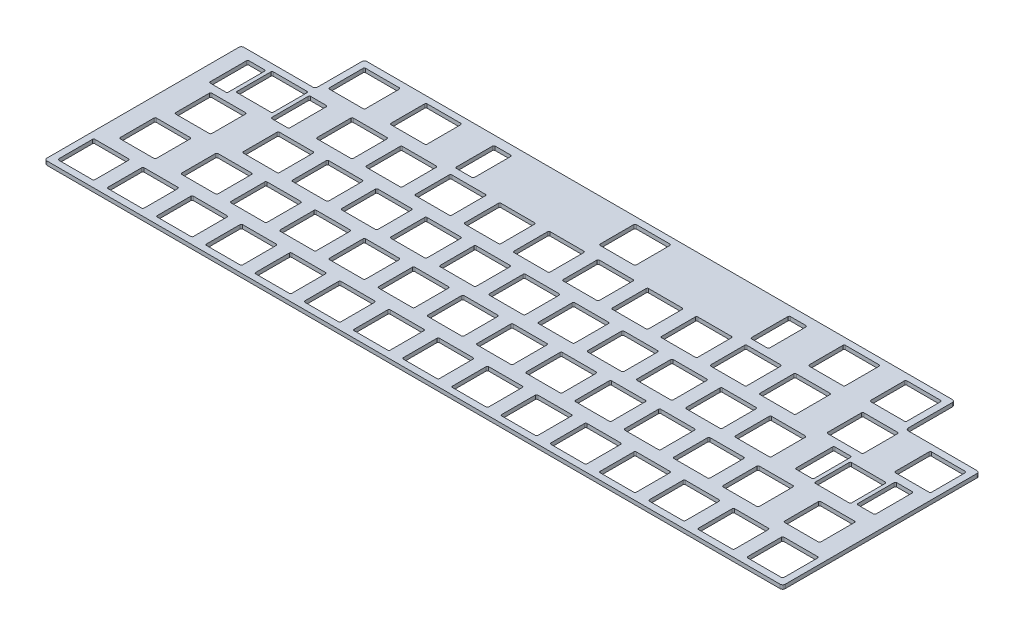
from build123d import *

# Parameters (mm, degrees)
BOSS_EXTRUDE1_DEPTH = 1.5


with BuildPart() as part:
    # Sketch2 → Boss-Extrude1 (new body)
    with BuildSketch(Plane.XZ):
        with BuildLine():
            Line((29.575, -95.25), (256.175, -95.25))
            ThreePointArc((256.175, -95.25), (256.882106781, -94.957106781), (257.175, -94.25))
            Line((257.175, -94.25), (257.175, -77.2))
            ThreePointArc((257.175, -77.2), (257.467893219, -76.492893219), (258.175, -76.2))
            Line((258.175, -76.2), (284.75, -76.2))
            ThreePointArc((284.75, -76.2), (285.457106781, -75.907106781), (285.75, -75.2))
            Line((285.75, -75.2), (285.75, -1))
            ThreePointArc((285.75, -1), (285.457106781, -0.292893219), (284.75, 0))
            Line((284.75, 0), (1, 0))
            ThreePointArc((1, 0), (0.292893219, -0.292893219), (0, -1))
            Line((0, -1), (0, -75.2))
            ThreePointArc((0, -75.2), (0.292893219, -75.907106781), (1, -76.2))
            Line((1, -76.2), (27.575, -76.2))
            ThreePointArc((27.575, -76.2), (28.282106781, -76.492893219), (28.575, -77.2))
            Line((28.575, -77.2), (28.575, -94.25))
            ThreePointArc((28.575, -94.25), (28.867893219, -94.957106781), (29.575, -95.25))
        make_face()
        with BuildLine():
            Line((3.025, -2.525), (16.025, -2.525))
            ThreePointArc((16.025, -2.525), (16.378553391, -2.671446609), (16.525, -3.025))
            Line((16.525, -3.025), (16.525, -16.025))
            ThreePointArc((16.525, -16.025), (16.378553391, -16.378553391), (16.025, -16.525))
            Line((16.025, -16.525), (3.025, -16.525))
            ThreePointArc((3.025, -16.525), (2.671446609, -16.378553391), (2.525, -16.025))
            Line((2.525, -16.025), (2.525, -3.025))
            ThreePointArc((2.525, -3.025), (2.671446609, -2.671446609), (3.025, -2.525))
        make_face(mode=Mode.SUBTRACT)
        with BuildLine():
            Line((22.075, -2.525), (35.075, -2.525))
            ThreePointArc((35.075, -2.525), (35.428553391, -2.671446609), (35.575, -3.025))
            Line((35.575, -3.025), (35.575, -16.025))
            ThreePointArc((35.575, -16.025), (35.428553391, -16.378553391), (35.075, -16.525))
            Line((35.075, -16.525), (22.075, -16.525))
            ThreePointArc((22.075, -16.525), (21.721446609, -16.378553391), (21.575, -16.025))
            Line((21.575, -16.025), (21.575, -3.025))
            ThreePointArc((21.575, -3.025), (21.721446609, -2.671446609), (22.075, -2.525))
        make_face(mode=Mode.SUBTRACT)
        with BuildLine():
            Line((41.125, -2.525), (54.125, -2.525))
            ThreePointArc((54.125, -2.525), (54.478553391, -2.671446609), (54.625, -3.025))
            Line((54.625, -3.025), (54.625, -16.025))
            ThreePointArc((54.625, -16.025), (54.478553391, -16.378553391), (54.125, -16.525))
            Line((54.125, -16.525), (41.125, -16.525))
            ThreePointArc((41.125, -16.525), (40.771446609, -16.378553391), (40.625, -16.025))
            Line((40.625, -16.025), (40.625, -3.025))
            ThreePointArc((40.625, -3.025), (40.771446609, -2.671446609), (41.125, -2.525))
        make_face(mode=Mode.SUBTRACT)
        with BuildLine():
            Line((60.175, -2.525), (73.175, -2.525))
            ThreePointArc((73.175, -2.525), (73.528553391, -2.671446609), (73.675, -3.025))
            Line((73.675, -3.025), (73.675, -16.025))
            ThreePointArc((73.675, -16.025), (73.528553391, -16.378553391), (73.175, -16.525))
            Line((73.175, -16.525), (60.175, -16.525))
            ThreePointArc((60.175, -16.525), (59.821446609, -16.378553391), (59.675, -16.025))
            Line((59.675, -16.025), (59.675, -3.025))
            ThreePointArc((59.675, -3.025), (59.821446609, -2.671446609), (60.175, -2.525))
        make_face(mode=Mode.SUBTRACT)
        with BuildLine():
            Line((79.225, -2.525), (92.225, -2.525))
            ThreePointArc((92.225, -2.525), (92.578553391, -2.671446609), (92.725, -3.025))
            Line((92.725, -3.025), (92.725, -16.025))
            ThreePointArc((92.725, -16.025), (92.578553391, -16.378553391), (92.225, -16.525))
            Line((92.225, -16.525), (79.225, -16.525))
            ThreePointArc((79.225, -16.525), (78.871446609, -16.378553391), (78.725, -16.025))
            Line((78.725, -16.025), (78.725, -3.025))
            ThreePointArc((78.725, -3.025), (78.871446609, -2.671446609), (79.225, -2.525))
        make_face(mode=Mode.SUBTRACT)
        with BuildLine():
            Line((98.275, -2.525), (111.275, -2.525))
            ThreePointArc((111.275, -2.525), (111.628553391, -2.671446609), (111.775, -3.025))
            Line((111.775, -3.025), (111.775, -16.025))
            ThreePointArc((111.775, -16.025), (111.628553391, -16.378553391), (111.275, -16.525))
            Line((111.275, -16.525), (98.275, -16.525))
            ThreePointArc((98.275, -16.525), (97.921446609, -16.378553391), (97.775, -16.025))
            Line((97.775, -16.025), (97.775, -3.025))
            ThreePointArc((97.775, -3.025), (97.921446609, -2.671446609), (98.275, -2.525))
        make_face(mode=Mode.SUBTRACT)
        with BuildLine():
            Line((117.325, -2.525), (130.325, -2.525))
            ThreePointArc((130.325, -2.525), (130.678553391, -2.671446609), (130.825, -3.025))
            Line((130.825, -3.025), (130.825, -16.025))
            ThreePointArc((130.825, -16.025), (130.678553391, -16.378553391), (130.325, -16.525))
            Line((130.325, -16.525), (117.325, -16.525))
            ThreePointArc((117.325, -16.525), (116.971446609, -16.378553391), (116.825, -16.025))
            Line((116.825, -16.025), (116.825, -3.025))
            ThreePointArc((116.825, -3.025), (116.971446609, -2.671446609), (117.325, -2.525))
        make_face(mode=Mode.SUBTRACT)
        with BuildLine():
            Line((136.375, -2.525), (149.375, -2.525))
            ThreePointArc((149.375, -2.525), (149.728553391, -2.671446609), (149.875, -3.025))
            Line((149.875, -3.025), (149.875, -16.025))
            ThreePointArc((149.875, -16.025), (149.728553391, -16.378553391), (149.375, -16.525))
            Line((149.375, -16.525), (136.375, -16.525))
            ThreePointArc((136.375, -16.525), (136.021446609, -16.378553391), (135.875, -16.025))
            Line((135.875, -16.025), (135.875, -3.025))
            ThreePointArc((135.875, -3.025), (136.021446609, -2.671446609), (136.375, -2.525))
        make_face(mode=Mode.SUBTRACT)
        with BuildLine():
            Line((155.425, -2.525), (168.425, -2.525))
            ThreePointArc((168.425, -2.525), (168.778553391, -2.671446609), (168.925, -3.025))
            Line((168.925, -3.025), (168.925, -16.025))
            ThreePointArc((168.925, -16.025), (168.778553391, -16.378553391), (168.425, -16.525))
            Line((168.425, -16.525), (155.425, -16.525))
            ThreePointArc((155.425, -16.525), (155.071446609, -16.378553391), (154.925, -16.025))
            Line((154.925, -16.025), (154.925, -3.025))
            ThreePointArc((154.925, -3.025), (155.071446609, -2.671446609), (155.425, -2.525))
        make_face(mode=Mode.SUBTRACT)
        with BuildLine():
            Line((174.475, -2.525), (187.475, -2.525))
            ThreePointArc((187.475, -2.525), (187.828553391, -2.671446609), (187.975, -3.025))
            Line((187.975, -3.025), (187.975, -16.025))
            ThreePointArc((187.975, -16.025), (187.828553391, -16.378553391), (187.475, -16.525))
            Line((187.475, -16.525), (174.475, -16.525))
            ThreePointArc((174.475, -16.525), (174.121446609, -16.378553391), (173.975, -16.025))
            Line((173.975, -16.025), (173.975, -3.025))
            ThreePointArc((173.975, -3.025), (174.121446609, -2.671446609), (174.475, -2.525))
        make_face(mode=Mode.SUBTRACT)
        with BuildLine():
            Line((193.525, -2.525), (206.525, -2.525))
            ThreePointArc((206.525, -2.525), (206.878553391, -2.671446609), (207.025, -3.025))
            Line((207.025, -3.025), (207.025, -16.025))
            ThreePointArc((207.025, -16.025), (206.878553391, -16.378553391), (206.525, -16.525))
            Line((206.525, -16.525), (193.525, -16.525))
            ThreePointArc((193.525, -16.525), (193.171446609, -16.378553391), (193.025, -16.025))
            Line((193.025, -16.025), (193.025, -3.025))
            ThreePointArc((193.025, -3.025), (193.171446609, -2.671446609), (193.525, -2.525))
        make_face(mode=Mode.SUBTRACT)
        with BuildLine():
            Line((212.575, -2.525), (225.575, -2.525))
            ThreePointArc((225.575, -2.525), (225.928553391, -2.671446609), (226.075, -3.025))
            Line((226.075, -3.025), (226.075, -16.025))
            ThreePointArc((226.075, -16.025), (225.928553391, -16.378553391), (225.575, -16.525))
            Line((225.575, -16.525), (212.575, -16.525))
            ThreePointArc((212.575, -16.525), (212.221446609, -16.378553391), (212.075, -16.025))
            Line((212.075, -16.025), (212.075, -3.025))
            ThreePointArc((212.075, -3.025), (212.221446609, -2.671446609), (212.575, -2.525))
        make_face(mode=Mode.SUBTRACT)
        with BuildLine():
            Line((231.625, -2.525), (244.625, -2.525))
            ThreePointArc((244.625, -2.525), (244.978553391, -2.671446609), (245.125, -3.025))
            Line((245.125, -3.025), (245.125, -16.025))
            ThreePointArc((245.125, -16.025), (244.978553391, -16.378553391), (244.625, -16.525))
            Line((244.625, -16.525), (231.625, -16.525))
            ThreePointArc((231.625, -16.525), (231.271446609, -16.378553391), (231.125, -16.025))
            Line((231.125, -16.025), (231.125, -3.025))
            ThreePointArc((231.125, -3.025), (231.271446609, -2.671446609), (231.625, -2.525))
        make_face(mode=Mode.SUBTRACT)
        with BuildLine():
            Line((250.675, -2.525), (263.675, -2.525))
            ThreePointArc((263.675, -2.525), (264.028553391, -2.671446609), (264.175, -3.025))
            Line((264.175, -3.025), (264.175, -16.025))
            ThreePointArc((264.175, -16.025), (264.028553391, -16.378553391), (263.675, -16.525))
            Line((263.675, -16.525), (250.675, -16.525))
            ThreePointArc((250.675, -16.525), (250.321446609, -16.378553391), (250.175, -16.025))
            Line((250.175, -16.025), (250.175, -3.025))
            ThreePointArc((250.175, -3.025), (250.321446609, -2.671446609), (250.675, -2.525))
        make_face(mode=Mode.SUBTRACT)
        with BuildLine():
            Line((269.725, -2.525), (282.725, -2.525))
            ThreePointArc((282.725, -2.525), (283.078553391, -2.671446609), (283.225, -3.025))
            Line((283.225, -3.025), (283.225, -16.025))
            ThreePointArc((283.225, -16.025), (283.078553391, -16.378553391), (282.725, -16.525))
            Line((282.725, -16.525), (269.725, -16.525))
            ThreePointArc((269.725, -16.525), (269.371446609, -16.378553391), (269.225, -16.025))
            Line((269.225, -16.025), (269.225, -3.025))
            ThreePointArc((269.225, -3.025), (269.371446609, -2.671446609), (269.725, -2.525))
        make_face(mode=Mode.SUBTRACT)
        with BuildLine():
            Line((7.7875, -21.575), (20.7875, -21.575))
            ThreePointArc((20.7875, -21.575), (21.141053391, -21.721446609), (21.2875, -22.075))
            Line((21.2875, -22.075), (21.2875, -35.075))
            ThreePointArc((21.2875, -35.075), (21.141053391, -35.428553391), (20.7875, -35.575))
            Line((20.7875, -35.575), (7.7875, -35.575))
            ThreePointArc((7.7875, -35.575), (7.433946609, -35.428553391), (7.2875, -35.075))
            Line((7.2875, -35.075), (7.2875, -22.075))
            ThreePointArc((7.2875, -22.075), (7.433946609, -21.721446609), (7.7875, -21.575))
        make_face(mode=Mode.SUBTRACT)
        with BuildLine():
            Line((31.6, -21.575), (44.6, -21.575))
            ThreePointArc((44.6, -21.575), (44.953553391, -21.721446609), (45.1, -22.075))
            Line((45.1, -22.075), (45.1, -35.075))
            ThreePointArc((45.1, -35.075), (44.953553391, -35.428553391), (44.6, -35.575))
            Line((44.6, -35.575), (31.6, -35.575))
            ThreePointArc((31.6, -35.575), (31.246446609, -35.428553391), (31.1, -35.075))
            Line((31.1, -35.075), (31.1, -22.075))
            ThreePointArc((31.1, -22.075), (31.246446609, -21.721446609), (31.6, -21.575))
        make_face(mode=Mode.SUBTRACT)
        with BuildLine():
            Line((50.65, -21.575), (63.65, -21.575))
            ThreePointArc((63.65, -21.575), (64.003553391, -21.721446609), (64.15, -22.075))
            Line((64.15, -22.075), (64.15, -35.075))
            ThreePointArc((64.15, -35.075), (64.003553391, -35.428553391), (63.65, -35.575))
            Line((63.65, -35.575), (50.65, -35.575))
            ThreePointArc((50.65, -35.575), (50.296446609, -35.428553391), (50.15, -35.075))
            Line((50.15, -35.075), (50.15, -22.075))
            ThreePointArc((50.15, -22.075), (50.296446609, -21.721446609), (50.65, -21.575))
        make_face(mode=Mode.SUBTRACT)
        with BuildLine():
            Line((69.7, -21.575), (82.7, -21.575))
            ThreePointArc((82.7, -21.575), (83.053553391, -21.721446609), (83.2, -22.075))
            Line((83.2, -22.075), (83.2, -35.075))
            ThreePointArc((83.2, -35.075), (83.053553391, -35.428553391), (82.7, -35.575))
            Line((82.7, -35.575), (69.7, -35.575))
            ThreePointArc((69.7, -35.575), (69.346446609, -35.428553391), (69.2, -35.075))
            Line((69.2, -35.075), (69.2, -22.075))
            ThreePointArc((69.2, -22.075), (69.346446609, -21.721446609), (69.7, -21.575))
        make_face(mode=Mode.SUBTRACT)
        with BuildLine():
            Line((88.75, -21.575), (101.75, -21.575))
            ThreePointArc((101.75, -21.575), (102.103553391, -21.721446609), (102.25, -22.075))
            Line((102.25, -22.075), (102.25, -35.075))
            ThreePointArc((102.25, -35.075), (102.103553391, -35.428553391), (101.75, -35.575))
            Line((101.75, -35.575), (88.75, -35.575))
            ThreePointArc((88.75, -35.575), (88.396446609, -35.428553391), (88.25, -35.075))
            Line((88.25, -35.075), (88.25, -22.075))
            ThreePointArc((88.25, -22.075), (88.396446609, -21.721446609), (88.75, -21.575))
        make_face(mode=Mode.SUBTRACT)
        with BuildLine():
            Line((107.8, -21.575), (120.8, -21.575))
            ThreePointArc((120.8, -21.575), (121.153553391, -21.721446609), (121.3, -22.075))
            Line((121.3, -22.075), (121.3, -35.075))
            ThreePointArc((121.3, -35.075), (121.153553391, -35.428553391), (120.8, -35.575))
            Line((120.8, -35.575), (107.8, -35.575))
            ThreePointArc((107.8, -35.575), (107.446446609, -35.428553391), (107.3, -35.075))
            Line((107.3, -35.075), (107.3, -22.075))
            ThreePointArc((107.3, -22.075), (107.446446609, -21.721446609), (107.8, -21.575))
        make_face(mode=Mode.SUBTRACT)
        with BuildLine():
            Line((126.85, -21.575), (139.85, -21.575))
            ThreePointArc((139.85, -21.575), (140.203553391, -21.721446609), (140.35, -22.075))
            Line((140.35, -22.075), (140.35, -35.075))
            ThreePointArc((140.35, -35.075), (140.203553391, -35.428553391), (139.85, -35.575))
            Line((139.85, -35.575), (126.85, -35.575))
            ThreePointArc((126.85, -35.575), (126.496446609, -35.428553391), (126.35, -35.075))
            Line((126.35, -35.075), (126.35, -22.075))
            ThreePointArc((126.35, -22.075), (126.496446609, -21.721446609), (126.85, -21.575))
        make_face(mode=Mode.SUBTRACT)
        with BuildLine():
            Line((145.9, -21.575), (158.9, -21.575))
            ThreePointArc((158.9, -21.575), (159.253553391, -21.721446609), (159.4, -22.075))
            Line((159.4, -22.075), (159.4, -35.075))
            ThreePointArc((159.4, -35.075), (159.253553391, -35.428553391), (158.9, -35.575))
            Line((158.9, -35.575), (145.9, -35.575))
            ThreePointArc((145.9, -35.575), (145.546446609, -35.428553391), (145.4, -35.075))
            Line((145.4, -35.075), (145.4, -22.075))
            ThreePointArc((145.4, -22.075), (145.546446609, -21.721446609), (145.9, -21.575))
        make_face(mode=Mode.SUBTRACT)
        with BuildLine():
            Line((164.95, -21.575), (177.95, -21.575))
            ThreePointArc((177.95, -21.575), (178.303553391, -21.721446609), (178.45, -22.075))
            Line((178.45, -22.075), (178.45, -35.075))
            ThreePointArc((178.45, -35.075), (178.303553391, -35.428553391), (177.95, -35.575))
            Line((177.95, -35.575), (164.95, -35.575))
            ThreePointArc((164.95, -35.575), (164.596446609, -35.428553391), (164.45, -35.075))
            Line((164.45, -35.075), (164.45, -22.075))
            ThreePointArc((164.45, -22.075), (164.596446609, -21.721446609), (164.95, -21.575))
        make_face(mode=Mode.SUBTRACT)
        with BuildLine():
            Line((184, -21.575), (197, -21.575))
            ThreePointArc((197, -21.575), (197.353553391, -21.721446609), (197.5, -22.075))
            Line((197.5, -22.075), (197.5, -35.075))
            ThreePointArc((197.5, -35.075), (197.353553391, -35.428553391), (197, -35.575))
            Line((197, -35.575), (184, -35.575))
            ThreePointArc((184, -35.575), (183.646446609, -35.428553391), (183.5, -35.075))
            Line((183.5, -35.075), (183.5, -22.075))
            ThreePointArc((183.5, -22.075), (183.646446609, -21.721446609), (184, -21.575))
        make_face(mode=Mode.SUBTRACT)
        with BuildLine():
            Line((203.05, -21.575), (216.05, -21.575))
            ThreePointArc((216.05, -21.575), (216.403553391, -21.721446609), (216.55, -22.075))
            Line((216.55, -22.075), (216.55, -35.075))
            ThreePointArc((216.55, -35.075), (216.403553391, -35.428553391), (216.05, -35.575))
            Line((216.05, -35.575), (203.05, -35.575))
            ThreePointArc((203.05, -35.575), (202.696446609, -35.428553391), (202.55, -35.075))
            Line((202.55, -35.075), (202.55, -22.075))
            ThreePointArc((202.55, -22.075), (202.696446609, -21.721446609), (203.05, -21.575))
        make_face(mode=Mode.SUBTRACT)
        with BuildLine():
            Line((222.1, -21.575), (235.1, -21.575))
            ThreePointArc((235.1, -21.575), (235.453553391, -21.721446609), (235.6, -22.075))
            Line((235.6, -22.075), (235.6, -35.075))
            ThreePointArc((235.6, -35.075), (235.453553391, -35.428553391), (235.1, -35.575))
            Line((235.1, -35.575), (222.1, -35.575))
            ThreePointArc((222.1, -35.575), (221.746446609, -35.428553391), (221.6, -35.075))
            Line((221.6, -35.075), (221.6, -22.075))
            ThreePointArc((221.6, -22.075), (221.746446609, -21.721446609), (222.1, -21.575))
        make_face(mode=Mode.SUBTRACT)
        with BuildLine():
            Line((241.15, -21.575), (254.15, -21.575))
            ThreePointArc((254.15, -21.575), (254.503553391, -21.721446609), (254.65, -22.075))
            Line((254.65, -22.075), (254.65, -35.075))
            ThreePointArc((254.65, -35.075), (254.503553391, -35.428553391), (254.15, -35.575))
            Line((254.15, -35.575), (241.15, -35.575))
            ThreePointArc((241.15, -35.575), (240.796446609, -35.428553391), (240.65, -35.075))
            Line((240.65, -35.075), (240.65, -22.075))
            ThreePointArc((240.65, -22.075), (240.796446609, -21.721446609), (241.15, -21.575))
        make_face(mode=Mode.SUBTRACT)
        with BuildLine():
            Line((264.9625, -21.575), (277.9625, -21.575))
            ThreePointArc((277.9625, -21.575), (278.316053391, -21.721446609), (278.4625, -22.075))
            Line((278.4625, -22.075), (278.4625, -35.075))
            ThreePointArc((278.4625, -35.075), (278.316053391, -35.428553391), (277.9625, -35.575))
            Line((277.9625, -35.575), (264.9625, -35.575))
            ThreePointArc((264.9625, -35.575), (264.608946609, -35.428553391), (264.4625, -35.075))
            Line((264.4625, -35.075), (264.4625, -22.075))
            ThreePointArc((264.4625, -22.075), (264.608946609, -21.721446609), (264.9625, -21.575))
        make_face(mode=Mode.SUBTRACT)
        with BuildLine():
            Line((10.16875, -40.625), (23.16875, -40.625))
            ThreePointArc((23.16875, -40.625), (23.522303391, -40.771446609), (23.66875, -41.125))
            Line((23.66875, -41.125), (23.66875, -54.125))
            ThreePointArc((23.66875, -54.125), (23.522303391, -54.478553391), (23.16875, -54.625))
            Line((23.16875, -54.625), (10.16875, -54.625))
            ThreePointArc((10.16875, -54.625), (9.815196609, -54.478553391), (9.66875, -54.125))
            Line((9.66875, -54.125), (9.66875, -41.125))
            ThreePointArc((9.66875, -41.125), (9.815196609, -40.771446609), (10.16875, -40.625))
        make_face(mode=Mode.SUBTRACT)
        with BuildLine():
            Line((36.3625, -40.625), (49.3625, -40.625))
            ThreePointArc((49.3625, -40.625), (49.716053391, -40.771446609), (49.8625, -41.125))
            Line((49.8625, -41.125), (49.8625, -54.125))
            ThreePointArc((49.8625, -54.125), (49.716053391, -54.478553391), (49.3625, -54.625))
            Line((49.3625, -54.625), (36.3625, -54.625))
            ThreePointArc((36.3625, -54.625), (36.008946609, -54.478553391), (35.8625, -54.125))
            Line((35.8625, -54.125), (35.8625, -41.125))
            ThreePointArc((35.8625, -41.125), (36.008946609, -40.771446609), (36.3625, -40.625))
        make_face(mode=Mode.SUBTRACT)
        with BuildLine():
            Line((55.4125, -40.625), (68.4125, -40.625))
            ThreePointArc((68.4125, -40.625), (68.766053391, -40.771446609), (68.9125, -41.125))
            Line((68.9125, -41.125), (68.9125, -54.125))
            ThreePointArc((68.9125, -54.125), (68.766053391, -54.478553391), (68.4125, -54.625))
            Line((68.4125, -54.625), (55.4125, -54.625))
            ThreePointArc((55.4125, -54.625), (55.058946609, -54.478553391), (54.9125, -54.125))
            Line((54.9125, -54.125), (54.9125, -41.125))
            ThreePointArc((54.9125, -41.125), (55.058946609, -40.771446609), (55.4125, -40.625))
        make_face(mode=Mode.SUBTRACT)
        with BuildLine():
            Line((74.4625, -40.625), (87.4625, -40.625))
            ThreePointArc((87.4625, -40.625), (87.816053391, -40.771446609), (87.9625, -41.125))
            Line((87.9625, -41.125), (87.9625, -54.125))
            ThreePointArc((87.9625, -54.125), (87.816053391, -54.478553391), (87.4625, -54.625))
            Line((87.4625, -54.625), (74.4625, -54.625))
            ThreePointArc((74.4625, -54.625), (74.108946609, -54.478553391), (73.9625, -54.125))
            Line((73.9625, -54.125), (73.9625, -41.125))
            ThreePointArc((73.9625, -41.125), (74.108946609, -40.771446609), (74.4625, -40.625))
        make_face(mode=Mode.SUBTRACT)
        with BuildLine():
            Line((93.5125, -40.625), (106.5125, -40.625))
            ThreePointArc((106.5125, -40.625), (106.866053391, -40.771446609), (107.0125, -41.125))
            Line((107.0125, -41.125), (107.0125, -54.125))
            ThreePointArc((107.0125, -54.125), (106.866053391, -54.478553391), (106.5125, -54.625))
            Line((106.5125, -54.625), (93.5125, -54.625))
            ThreePointArc((93.5125, -54.625), (93.158946609, -54.478553391), (93.0125, -54.125))
            Line((93.0125, -54.125), (93.0125, -41.125))
            ThreePointArc((93.0125, -41.125), (93.158946609, -40.771446609), (93.5125, -40.625))
        make_face(mode=Mode.SUBTRACT)
        with BuildLine():
            Line((112.5625, -40.625), (125.5625, -40.625))
            ThreePointArc((125.5625, -40.625), (125.916053391, -40.771446609), (126.0625, -41.125))
            Line((126.0625, -41.125), (126.0625, -54.125))
            ThreePointArc((126.0625, -54.125), (125.916053391, -54.478553391), (125.5625, -54.625))
            Line((125.5625, -54.625), (112.5625, -54.625))
            ThreePointArc((112.5625, -54.625), (112.208946609, -54.478553391), (112.0625, -54.125))
            Line((112.0625, -54.125), (112.0625, -41.125))
            ThreePointArc((112.0625, -41.125), (112.208946609, -40.771446609), (112.5625, -40.625))
        make_face(mode=Mode.SUBTRACT)
        with BuildLine():
            Line((131.6125, -40.625), (144.6125, -40.625))
            ThreePointArc((144.6125, -40.625), (144.966053391, -40.771446609), (145.1125, -41.125))
            Line((145.1125, -41.125), (145.1125, -54.125))
            ThreePointArc((145.1125, -54.125), (144.966053391, -54.478553391), (144.6125, -54.625))
            Line((144.6125, -54.625), (131.6125, -54.625))
            ThreePointArc((131.6125, -54.625), (131.258946609, -54.478553391), (131.1125, -54.125))
            Line((131.1125, -54.125), (131.1125, -41.125))
            ThreePointArc((131.1125, -41.125), (131.258946609, -40.771446609), (131.6125, -40.625))
        make_face(mode=Mode.SUBTRACT)
        with BuildLine():
            Line((150.6625, -40.625), (163.6625, -40.625))
            ThreePointArc((163.6625, -40.625), (164.016053391, -40.771446609), (164.1625, -41.125))
            Line((164.1625, -41.125), (164.1625, -54.125))
            ThreePointArc((164.1625, -54.125), (164.016053391, -54.478553391), (163.6625, -54.625))
            Line((163.6625, -54.625), (150.6625, -54.625))
            ThreePointArc((150.6625, -54.625), (150.308946609, -54.478553391), (150.1625, -54.125))
            Line((150.1625, -54.125), (150.1625, -41.125))
            ThreePointArc((150.1625, -41.125), (150.308946609, -40.771446609), (150.6625, -40.625))
        make_face(mode=Mode.SUBTRACT)
        with BuildLine():
            Line((169.7125, -40.625), (182.7125, -40.625))
            ThreePointArc((182.7125, -40.625), (183.066053391, -40.771446609), (183.2125, -41.125))
            Line((183.2125, -41.125), (183.2125, -54.125))
            ThreePointArc((183.2125, -54.125), (183.066053391, -54.478553391), (182.7125, -54.625))
            Line((182.7125, -54.625), (169.7125, -54.625))
            ThreePointArc((169.7125, -54.625), (169.358946609, -54.478553391), (169.2125, -54.125))
            Line((169.2125, -54.125), (169.2125, -41.125))
            ThreePointArc((169.2125, -41.125), (169.358946609, -40.771446609), (169.7125, -40.625))
        make_face(mode=Mode.SUBTRACT)
        with BuildLine():
            Line((188.7625, -40.625), (201.7625, -40.625))
            ThreePointArc((201.7625, -40.625), (202.116053391, -40.771446609), (202.2625, -41.125))
            Line((202.2625, -41.125), (202.2625, -54.125))
            ThreePointArc((202.2625, -54.125), (202.116053391, -54.478553391), (201.7625, -54.625))
            Line((201.7625, -54.625), (188.7625, -54.625))
            ThreePointArc((188.7625, -54.625), (188.408946609, -54.478553391), (188.2625, -54.125))
            Line((188.2625, -54.125), (188.2625, -41.125))
            ThreePointArc((188.2625, -41.125), (188.408946609, -40.771446609), (188.7625, -40.625))
        make_face(mode=Mode.SUBTRACT)
        with BuildLine():
            Line((207.8125, -40.625), (220.8125, -40.625))
            ThreePointArc((220.8125, -40.625), (221.166053391, -40.771446609), (221.3125, -41.125))
            Line((221.3125, -41.125), (221.3125, -54.125))
            ThreePointArc((221.3125, -54.125), (221.166053391, -54.478553391), (220.8125, -54.625))
            Line((220.8125, -54.625), (207.8125, -54.625))
            ThreePointArc((207.8125, -54.625), (207.458946609, -54.478553391), (207.3125, -54.125))
            Line((207.3125, -54.125), (207.3125, -41.125))
            ThreePointArc((207.3125, -41.125), (207.458946609, -40.771446609), (207.8125, -40.625))
        make_face(mode=Mode.SUBTRACT)
        with BuildLine():
            Line((226.8625, -40.625), (239.8625, -40.625))
            ThreePointArc((239.8625, -40.625), (240.216053391, -40.771446609), (240.3625, -41.125))
            Line((240.3625, -41.125), (240.3625, -54.125))
            ThreePointArc((240.3625, -54.125), (240.216053391, -54.478553391), (239.8625, -54.625))
            Line((239.8625, -54.625), (226.8625, -54.625))
            ThreePointArc((226.8625, -54.625), (226.508946609, -54.478553391), (226.3625, -54.125))
            Line((226.3625, -54.125), (226.3625, -41.125))
            ThreePointArc((226.3625, -41.125), (226.508946609, -40.771446609), (226.8625, -40.625))
        make_face(mode=Mode.SUBTRACT)
        with BuildLine():
            Line((257.81875, -40.625), (270.81875, -40.625))
            ThreePointArc((270.81875, -40.625), (271.172303391, -40.771446609), (271.31875, -41.125))
            Line((271.31875, -41.125), (271.31875, -54.125))
            ThreePointArc((271.31875, -54.125), (271.172303391, -54.478553391), (270.81875, -54.625))
            Line((270.81875, -54.625), (257.81875, -54.625))
            ThreePointArc((257.81875, -54.625), (257.465196609, -54.478553391), (257.31875, -54.125))
            Line((257.31875, -54.125), (257.31875, -41.125))
            ThreePointArc((257.31875, -41.125), (257.465196609, -40.771446609), (257.81875, -40.625))
        make_face(mode=Mode.SUBTRACT)
        with BuildLine():
            Line((249.38075, -41.625), (255.38075, -41.625))
            ThreePointArc((255.38075, -41.625), (255.734303391, -41.771446609), (255.88075, -42.125))
            Line((255.88075, -42.125), (255.88075, -56.125))
            ThreePointArc((255.88075, -56.125), (255.734303391, -56.478553391), (255.38075, -56.625))
            Line((255.38075, -56.625), (249.38075, -56.625))
            ThreePointArc((249.38075, -56.625), (249.027196609, -56.478553391), (248.88075, -56.125))
            Line((248.88075, -56.125), (248.88075, -42.125))
            ThreePointArc((248.88075, -42.125), (249.027196609, -41.771446609), (249.38075, -41.625))
        make_face(mode=Mode.SUBTRACT)
        with BuildLine():
            Line((273.25675, -41.625), (279.25675, -41.625))
            ThreePointArc((279.25675, -41.625), (279.610303391, -41.771446609), (279.75675, -42.125))
            Line((279.75675, -42.125), (279.75675, -56.125))
            ThreePointArc((279.75675, -56.125), (279.610303391, -56.478553391), (279.25675, -56.625))
            Line((279.25675, -56.625), (273.25675, -56.625))
            ThreePointArc((273.25675, -56.625), (272.903196609, -56.478553391), (272.75675, -56.125))
            Line((272.75675, -56.125), (272.75675, -42.125))
            ThreePointArc((272.75675, -42.125), (272.903196609, -41.771446609), (273.25675, -41.625))
        make_face(mode=Mode.SUBTRACT)
        with BuildLine():
            Line((14.93125, -59.675), (27.93125, -59.675))
            ThreePointArc((27.93125, -59.675), (28.284803391, -59.821446609), (28.43125, -60.175))
            Line((28.43125, -60.175), (28.43125, -73.175))
            ThreePointArc((28.43125, -73.175), (28.284803391, -73.528553391), (27.93125, -73.675))
            Line((27.93125, -73.675), (14.93125, -73.675))
            ThreePointArc((14.93125, -73.675), (14.577696609, -73.528553391), (14.43125, -73.175))
            Line((14.43125, -73.175), (14.43125, -60.175))
            ThreePointArc((14.43125, -60.175), (14.577696609, -59.821446609), (14.93125, -59.675))
        make_face(mode=Mode.SUBTRACT)
        with BuildLine():
            Line((36.36925, -72.675), (30.36925, -72.675))
            ThreePointArc((30.36925, -72.675), (30.015696609, -72.528553391), (29.86925, -72.175))
            Line((29.86925, -72.175), (29.86925, -58.175))
            ThreePointArc((29.86925, -58.175), (30.015696609, -57.821446609), (30.36925, -57.675))
            Line((30.36925, -57.675), (36.36925, -57.675))
            ThreePointArc((36.36925, -57.675), (36.722803391, -57.821446609), (36.86925, -58.175))
            Line((36.86925, -58.175), (36.86925, -72.175))
            ThreePointArc((36.86925, -72.175), (36.722803391, -72.528553391), (36.36925, -72.675))
        make_face(mode=Mode.SUBTRACT)
        with BuildLine():
            Line((12.49325, -72.675), (6.49325, -72.675))
            ThreePointArc((6.49325, -72.675), (6.139696609, -72.528553391), (5.99325, -72.175))
            Line((5.99325, -72.175), (5.99325, -58.175))
            ThreePointArc((5.99325, -58.175), (6.139696609, -57.821446609), (6.49325, -57.675))
            Line((6.49325, -57.675), (12.49325, -57.675))
            ThreePointArc((12.49325, -57.675), (12.846803391, -57.821446609), (12.99325, -58.175))
            Line((12.99325, -58.175), (12.99325, -72.175))
            ThreePointArc((12.99325, -72.175), (12.846803391, -72.528553391), (12.49325, -72.675))
        make_face(mode=Mode.SUBTRACT)
        with BuildLine():
            Line((45.8875, -59.675), (58.8875, -59.675))
            ThreePointArc((58.8875, -59.675), (59.241053391, -59.821446609), (59.3875, -60.175))
            Line((59.3875, -60.175), (59.3875, -73.175))
            ThreePointArc((59.3875, -73.175), (59.241053391, -73.528553391), (58.8875, -73.675))
            Line((58.8875, -73.675), (45.8875, -73.675))
            ThreePointArc((45.8875, -73.675), (45.533946609, -73.528553391), (45.3875, -73.175))
            Line((45.3875, -73.175), (45.3875, -60.175))
            ThreePointArc((45.3875, -60.175), (45.533946609, -59.821446609), (45.8875, -59.675))
        make_face(mode=Mode.SUBTRACT)
        with BuildLine():
            Line((64.9375, -59.675), (77.9375, -59.675))
            ThreePointArc((77.9375, -59.675), (78.291053391, -59.821446609), (78.4375, -60.175))
            Line((78.4375, -60.175), (78.4375, -73.175))
            ThreePointArc((78.4375, -73.175), (78.291053391, -73.528553391), (77.9375, -73.675))
            Line((77.9375, -73.675), (64.9375, -73.675))
            ThreePointArc((64.9375, -73.675), (64.583946609, -73.528553391), (64.4375, -73.175))
            Line((64.4375, -73.175), (64.4375, -60.175))
            ThreePointArc((64.4375, -60.175), (64.583946609, -59.821446609), (64.9375, -59.675))
        make_face(mode=Mode.SUBTRACT)
        with BuildLine():
            Line((83.9875, -59.675), (96.9875, -59.675))
            ThreePointArc((96.9875, -59.675), (97.341053391, -59.821446609), (97.4875, -60.175))
            Line((97.4875, -60.175), (97.4875, -73.175))
            ThreePointArc((97.4875, -73.175), (97.341053391, -73.528553391), (96.9875, -73.675))
            Line((96.9875, -73.675), (83.9875, -73.675))
            ThreePointArc((83.9875, -73.675), (83.633946609, -73.528553391), (83.4875, -73.175))
            Line((83.4875, -73.175), (83.4875, -60.175))
            ThreePointArc((83.4875, -60.175), (83.633946609, -59.821446609), (83.9875, -59.675))
        make_face(mode=Mode.SUBTRACT)
        with BuildLine():
            Line((103.0375, -59.675), (116.0375, -59.675))
            ThreePointArc((116.0375, -59.675), (116.391053391, -59.821446609), (116.5375, -60.175))
            Line((116.5375, -60.175), (116.5375, -73.175))
            ThreePointArc((116.5375, -73.175), (116.391053391, -73.528553391), (116.0375, -73.675))
            Line((116.0375, -73.675), (103.0375, -73.675))
            ThreePointArc((103.0375, -73.675), (102.683946609, -73.528553391), (102.5375, -73.175))
            Line((102.5375, -73.175), (102.5375, -60.175))
            ThreePointArc((102.5375, -60.175), (102.683946609, -59.821446609), (103.0375, -59.675))
        make_face(mode=Mode.SUBTRACT)
        with BuildLine():
            Line((122.0875, -59.675), (135.0875, -59.675))
            ThreePointArc((135.0875, -59.675), (135.441053391, -59.821446609), (135.5875, -60.175))
            Line((135.5875, -60.175), (135.5875, -73.175))
            ThreePointArc((135.5875, -73.175), (135.441053391, -73.528553391), (135.0875, -73.675))
            Line((135.0875, -73.675), (122.0875, -73.675))
            ThreePointArc((122.0875, -73.675), (121.733946609, -73.528553391), (121.5875, -73.175))
            Line((121.5875, -73.175), (121.5875, -60.175))
            ThreePointArc((121.5875, -60.175), (121.733946609, -59.821446609), (122.0875, -59.675))
        make_face(mode=Mode.SUBTRACT)
        with BuildLine():
            Line((141.1375, -59.675), (154.1375, -59.675))
            ThreePointArc((154.1375, -59.675), (154.491053391, -59.821446609), (154.6375, -60.175))
            Line((154.6375, -60.175), (154.6375, -73.175))
            ThreePointArc((154.6375, -73.175), (154.491053391, -73.528553391), (154.1375, -73.675))
            Line((154.1375, -73.675), (141.1375, -73.675))
            ThreePointArc((141.1375, -73.675), (140.783946609, -73.528553391), (140.6375, -73.175))
            Line((140.6375, -73.175), (140.6375, -60.175))
            ThreePointArc((140.6375, -60.175), (140.783946609, -59.821446609), (141.1375, -59.675))
        make_face(mode=Mode.SUBTRACT)
        with BuildLine():
            Line((160.1875, -59.675), (173.1875, -59.675))
            ThreePointArc((173.1875, -59.675), (173.541053391, -59.821446609), (173.6875, -60.175))
            Line((173.6875, -60.175), (173.6875, -73.175))
            ThreePointArc((173.6875, -73.175), (173.541053391, -73.528553391), (173.1875, -73.675))
            Line((173.1875, -73.675), (160.1875, -73.675))
            ThreePointArc((160.1875, -73.675), (159.833946609, -73.528553391), (159.6875, -73.175))
            Line((159.6875, -73.175), (159.6875, -60.175))
            ThreePointArc((159.6875, -60.175), (159.833946609, -59.821446609), (160.1875, -59.675))
        make_face(mode=Mode.SUBTRACT)
        with BuildLine():
            Line((179.2375, -59.675), (192.2375, -59.675))
            ThreePointArc((192.2375, -59.675), (192.591053391, -59.821446609), (192.7375, -60.175))
            Line((192.7375, -60.175), (192.7375, -73.175))
            ThreePointArc((192.7375, -73.175), (192.591053391, -73.528553391), (192.2375, -73.675))
            Line((192.2375, -73.675), (179.2375, -73.675))
            ThreePointArc((179.2375, -73.675), (178.883946609, -73.528553391), (178.7375, -73.175))
            Line((178.7375, -73.175), (178.7375, -60.175))
            ThreePointArc((178.7375, -60.175), (178.883946609, -59.821446609), (179.2375, -59.675))
        make_face(mode=Mode.SUBTRACT)
        with BuildLine():
            Line((198.2875, -59.675), (211.2875, -59.675))
            ThreePointArc((211.2875, -59.675), (211.641053391, -59.821446609), (211.7875, -60.175))
            Line((211.7875, -60.175), (211.7875, -73.175))
            ThreePointArc((211.7875, -73.175), (211.641053391, -73.528553391), (211.2875, -73.675))
            Line((211.2875, -73.675), (198.2875, -73.675))
            ThreePointArc((198.2875, -73.675), (197.933946609, -73.528553391), (197.7875, -73.175))
            Line((197.7875, -73.175), (197.7875, -60.175))
            ThreePointArc((197.7875, -60.175), (197.933946609, -59.821446609), (198.2875, -59.675))
        make_face(mode=Mode.SUBTRACT)
        with BuildLine():
            Line((217.3375, -59.675), (230.3375, -59.675))
            ThreePointArc((230.3375, -59.675), (230.691053391, -59.821446609), (230.8375, -60.175))
            Line((230.8375, -60.175), (230.8375, -73.175))
            ThreePointArc((230.8375, -73.175), (230.691053391, -73.528553391), (230.3375, -73.675))
            Line((230.3375, -73.675), (217.3375, -73.675))
            ThreePointArc((217.3375, -73.675), (216.983946609, -73.528553391), (216.8375, -73.175))
            Line((216.8375, -73.175), (216.8375, -60.175))
            ThreePointArc((216.8375, -60.175), (216.983946609, -59.821446609), (217.3375, -59.675))
        make_face(mode=Mode.SUBTRACT)
        with BuildLine():
            Line((243.53125, -59.675), (256.53125, -59.675))
            ThreePointArc((256.53125, -59.675), (256.884803391, -59.821446609), (257.03125, -60.175))
            Line((257.03125, -60.175), (257.03125, -73.175))
            ThreePointArc((257.03125, -73.175), (256.884803391, -73.528553391), (256.53125, -73.675))
            Line((256.53125, -73.675), (243.53125, -73.675))
            ThreePointArc((243.53125, -73.675), (243.177696609, -73.528553391), (243.03125, -73.175))
            Line((243.03125, -73.175), (243.03125, -60.175))
            ThreePointArc((243.03125, -60.175), (243.177696609, -59.821446609), (243.53125, -59.675))
        make_face(mode=Mode.SUBTRACT)
        with BuildLine():
            Line((269.725, -59.675), (282.725, -59.675))
            ThreePointArc((282.725, -59.675), (283.078553391, -59.821446609), (283.225, -60.175))
            Line((283.225, -60.175), (283.225, -73.175))
            ThreePointArc((283.225, -73.175), (283.078553391, -73.528553391), (282.725, -73.675))
            Line((282.725, -73.675), (269.725, -73.675))
            ThreePointArc((269.725, -73.675), (269.371446609, -73.528553391), (269.225, -73.175))
            Line((269.225, -73.175), (269.225, -60.175))
            ThreePointArc((269.225, -60.175), (269.371446609, -59.821446609), (269.725, -59.675))
        make_face(mode=Mode.SUBTRACT)
        with BuildLine():
            Line((31.6, -78.725), (44.6, -78.725))
            ThreePointArc((44.6, -78.725), (44.953553391, -78.871446609), (45.1, -79.225))
            Line((45.1, -79.225), (45.1, -92.225))
            ThreePointArc((45.1, -92.225), (44.953553391, -92.578553391), (44.6, -92.725))
            Line((44.6, -92.725), (31.6, -92.725))
            ThreePointArc((31.6, -92.725), (31.246446609, -92.578553391), (31.1, -92.225))
            Line((31.1, -92.225), (31.1, -79.225))
            ThreePointArc((31.1, -79.225), (31.246446609, -78.871446609), (31.6, -78.725))
        make_face(mode=Mode.SUBTRACT)
        with BuildLine():
            Line((55.4125, -78.725), (68.4125, -78.725))
            ThreePointArc((68.4125, -78.725), (68.766053391, -78.871446609), (68.9125, -79.225))
            Line((68.9125, -79.225), (68.9125, -92.225))
            ThreePointArc((68.9125, -92.225), (68.766053391, -92.578553391), (68.4125, -92.725))
            Line((68.4125, -92.725), (55.4125, -92.725))
            ThreePointArc((55.4125, -92.725), (55.058946609, -92.578553391), (54.9125, -92.225))
            Line((54.9125, -92.225), (54.9125, -79.225))
            ThreePointArc((54.9125, -79.225), (55.058946609, -78.871446609), (55.4125, -78.725))
        make_face(mode=Mode.SUBTRACT)
        with BuildLine():
            Line((136.375, -78.725), (149.375, -78.725))
            ThreePointArc((149.375, -78.725), (149.728553391, -78.871446609), (149.875, -79.225))
            Line((149.875, -79.225), (149.875, -92.225))
            ThreePointArc((149.875, -92.225), (149.728553391, -92.578553391), (149.375, -92.725))
            Line((149.375, -92.725), (136.375, -92.725))
            ThreePointArc((136.375, -92.725), (136.021446609, -92.578553391), (135.875, -92.225))
            Line((135.875, -92.225), (135.875, -79.225))
            ThreePointArc((135.875, -79.225), (136.021446609, -78.871446609), (136.375, -78.725))
        make_face(mode=Mode.SUBTRACT)
        with BuildLine():
            Line((203.025, -91.725), (197.025, -91.725))
            ThreePointArc((197.025, -91.725), (196.671446609, -91.578553391), (196.525, -91.225))
            Line((196.525, -91.225), (196.525, -77.225))
            ThreePointArc((196.525, -77.225), (196.671446609, -76.871446609), (197.025, -76.725))
            Line((197.025, -76.725), (203.025, -76.725))
            ThreePointArc((203.025, -76.725), (203.378553391, -76.871446609), (203.525, -77.225))
            Line((203.525, -77.225), (203.525, -91.225))
            ThreePointArc((203.525, -91.225), (203.378553391, -91.578553391), (203.025, -91.725))
        make_face(mode=Mode.SUBTRACT)
        with BuildLine():
            Line((88.725, -91.725), (82.725, -91.725))
            ThreePointArc((82.725, -91.725), (82.371446609, -91.578553391), (82.225, -91.225))
            Line((82.225, -91.225), (82.225, -77.225))
            ThreePointArc((82.225, -77.225), (82.371446609, -76.871446609), (82.725, -76.725))
            Line((82.725, -76.725), (88.725, -76.725))
            ThreePointArc((88.725, -76.725), (89.078553391, -76.871446609), (89.225, -77.225))
            Line((89.225, -77.225), (89.225, -91.225))
            ThreePointArc((89.225, -91.225), (89.078553391, -91.578553391), (88.725, -91.725))
        make_face(mode=Mode.SUBTRACT)
        with BuildLine():
            Line((217.3375, -78.725), (230.3375, -78.725))
            ThreePointArc((230.3375, -78.725), (230.691053391, -78.871446609), (230.8375, -79.225))
            Line((230.8375, -79.225), (230.8375, -92.225))
            ThreePointArc((230.8375, -92.225), (230.691053391, -92.578553391), (230.3375, -92.725))
            Line((230.3375, -92.725), (217.3375, -92.725))
            ThreePointArc((217.3375, -92.725), (216.983946609, -92.578553391), (216.8375, -92.225))
            Line((216.8375, -92.225), (216.8375, -79.225))
            ThreePointArc((216.8375, -79.225), (216.983946609, -78.871446609), (217.3375, -78.725))
        make_face(mode=Mode.SUBTRACT)
        with BuildLine():
            Line((241.15, -78.725), (254.15, -78.725))
            ThreePointArc((254.15, -78.725), (254.503553391, -78.871446609), (254.65, -79.225))
            Line((254.65, -79.225), (254.65, -92.225))
            ThreePointArc((254.65, -92.225), (254.503553391, -92.578553391), (254.15, -92.725))
            Line((254.15, -92.725), (241.15, -92.725))
            ThreePointArc((241.15, -92.725), (240.796446609, -92.578553391), (240.65, -92.225))
            Line((240.65, -92.225), (240.65, -79.225))
            ThreePointArc((240.65, -79.225), (240.796446609, -78.871446609), (241.15, -78.725))
        make_face(mode=Mode.SUBTRACT)
    extrude(amount=BOSS_EXTRUDE1_DEPTH)


solid = part.part
